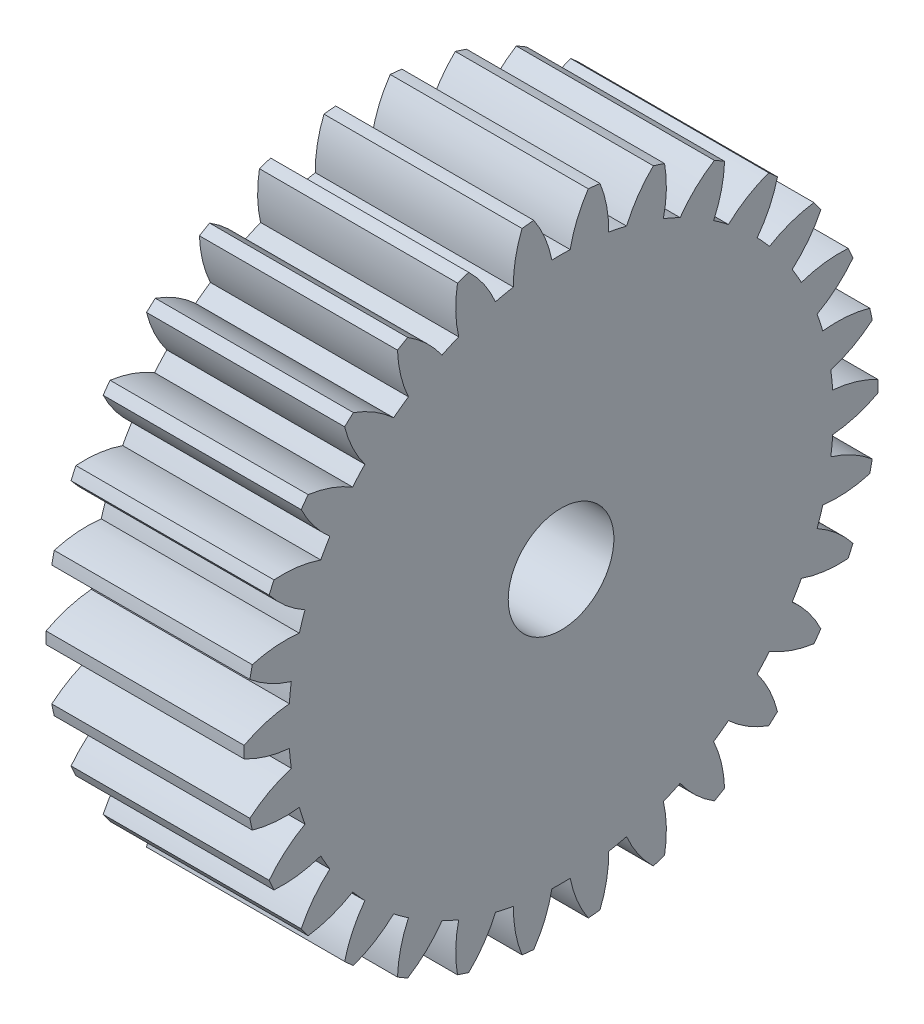
from build123d import *

# Parameters (mm, degrees)
BASPROSKE_W     = 15
BASPROSKE_H     = 24
TOOTHCUT_DEPTH  = 38.107950631
TEETHCUTS_COUNT = 30
TEETHCUTS_ANGLE = 348
BORSKE_R        = 4
BORE_DEPTH      = 50.0000508


with BuildPart() as part:
    # BasProSke → Base-Revolve (revolve)
    with BuildSketch(Plane(origin=(0, 0, 0), x_dir=(1, 0, 0), z_dir=(0, 1, 0)), mode=Mode.PRIVATE) as base_revolve_sk:
        with Locations((7.5, 12)):
            Rectangle(BASPROSKE_W, BASPROSKE_H)
    revolve(base_revolve_sk.sketch.rotate(Axis((-10, 0, 0), (1, 0, 0)), 180), axis=Axis((-10, 0, 0), (1, 0, 0)))

    # TooCutSke → ToothCut (cut, through all)
    with BuildSketch(Plane(origin=(0, 0, 0), x_dir=(0, 0, -1), z_dir=(1, 0, 0))):
        with BuildLine():
            ThreePointArc((0.693278797, 20.612344372), (0, 20.624), (-0.693278797, 20.612344372))
            ThreePointArc((-0.693278797, 20.612344372), (-1.219042225, 22.34383125), (-2.080549663, 23.935144835))
            ThreePointArc((-2.080549663, 23.935144835), (0, 24.0254), (2.080549663, 23.935144835))
            ThreePointArc((2.080549663, 23.935144835), (1.219042225, 22.34383125), (0.693278797, 20.612344372))
        make_face()
    toothcut = extrude(amount=TOOTHCUT_DEPTH, mode=Mode.SUBTRACT)

    # TeethCuts: ToothCut ×30 about axis
    teethcuts_axis = Axis((-10, 0, 0), (1, 0, 0))
    for i in range(1, TEETHCUTS_COUNT):
        add(toothcut.rotate(teethcuts_axis, i * TEETHCUTS_ANGLE / (TEETHCUTS_COUNT - 1)), mode=Mode.SUBTRACT)

    # BorSke → Bore (cut, symmetric)
    with BuildSketch(Plane(origin=(0, 0, 0), x_dir=(0, 0, -1), z_dir=(1, 0, 0))):
        with Locations(Location((0, 0, 0), (0, 0, 180))):
            Circle(BORSKE_R)
    extrude(amount=BORE_DEPTH, both=True, mode=Mode.SUBTRACT)


solid = part.part
